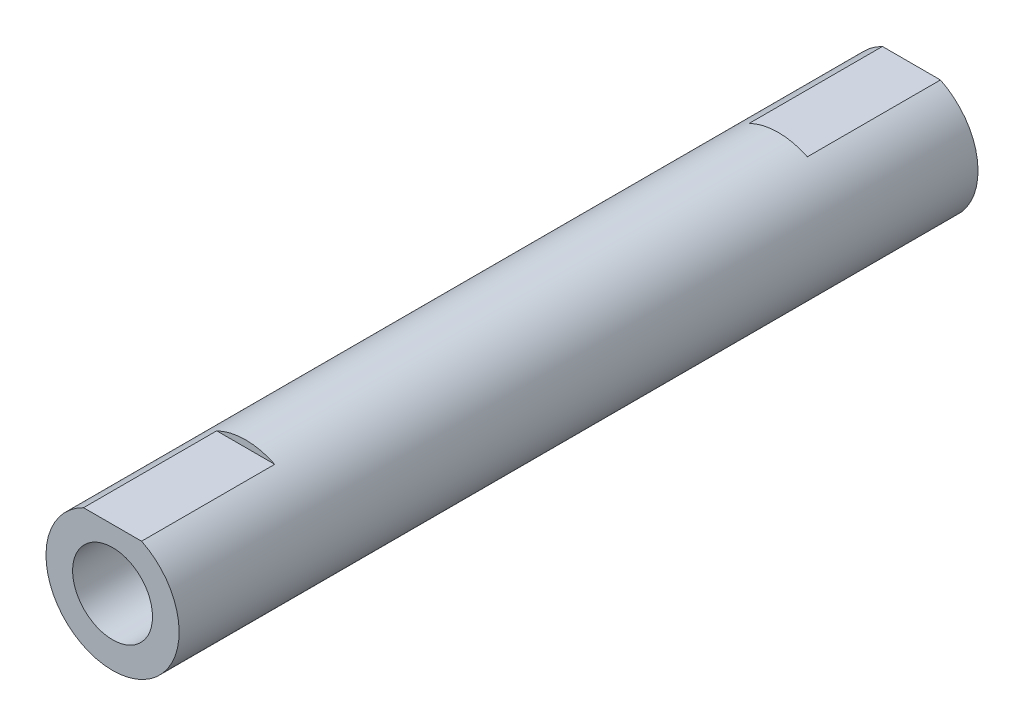
from build123d import *

# Parameters (mm, degrees)
SKETCH1_R           = 5
SKETCH1_R_2         = 3
BOSS_EXTRUDE1_DEPTH = 30
CUT_EXTRUDE1_START  = -10
CUT_EXTRUDE1_DEPTH  = 11


with BuildPart() as part:
    # Sketch1 → Boss-Extrude1 (new body, symmetric)
    with BuildSketch(Plane.XY):
        Circle(SKETCH1_R)
        Circle(SKETCH1_R_2, mode=Mode.SUBTRACT)
    extrude(amount=BOSS_EXTRUDE1_DEPTH, both=True)

    # Sketch4 → Cut-Extrude1 (cut)
    with BuildSketch(Plane.XY.offset(30).offset(CUT_EXTRUDE1_START)):
        with BuildLine():
            Line((-2.179449472, 4.5), (2.179449472, 4.5))
            ThreePointArc((2.179449472, 4.5), (0, 5), (-2.179449472, 4.5))
        make_face()
    cut_extrude1 = extrude(amount=CUT_EXTRUDE1_DEPTH, mode=Mode.SUBTRACT)

    # Mirror3: Cut-Extrude1 across plane
    add(cut_extrude1.mirror(Plane.XY), mode=Mode.SUBTRACT)


solid = part.part
